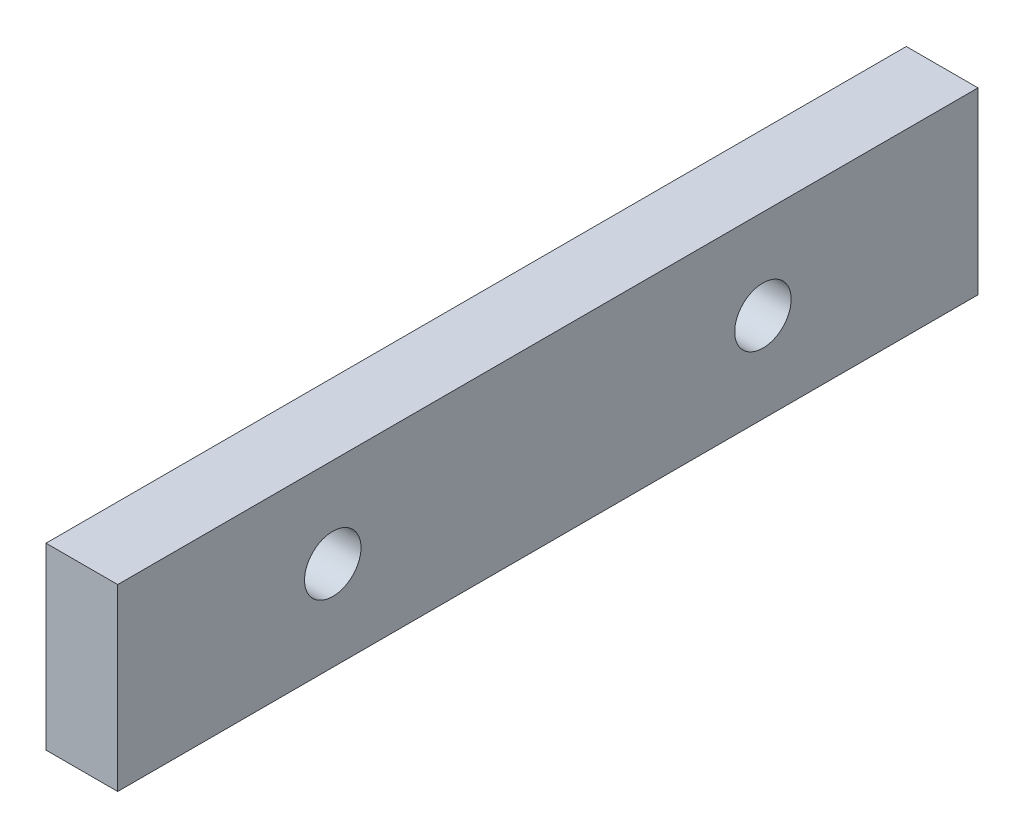
from build123d import *

# Parameters (mm, degrees)
SKETCH1_W                 = 6.35
SKETCH1_H                 = 15.875
EXTRUDE1_DEPTH            = 38.1
M6X1_0_TAPPED_HOLE1_D     = 5
M6X1_0_TAPPED_HOLE1_DEPTH = 6.35


with BuildPart() as part:
    # Sketch1 → Extrude1 (new body, symmetric)
    with BuildSketch(Plane.XY):
        Rectangle(SKETCH1_W, SKETCH1_H)
    extrude(amount=EXTRUDE1_DEPTH, both=True)

    # M6x1.0 Tapped Hole1
    with Locations(Plane(origin=(3.175, 0, 0), x_dir=(0, 0, -1), z_dir=(1, 0, 0))):
        with Locations((-19.05, 0), (19.05, 0)):
            Hole(M6X1_0_TAPPED_HOLE1_D / 2, depth=M6X1_0_TAPPED_HOLE1_DEPTH)


solid = part.part
